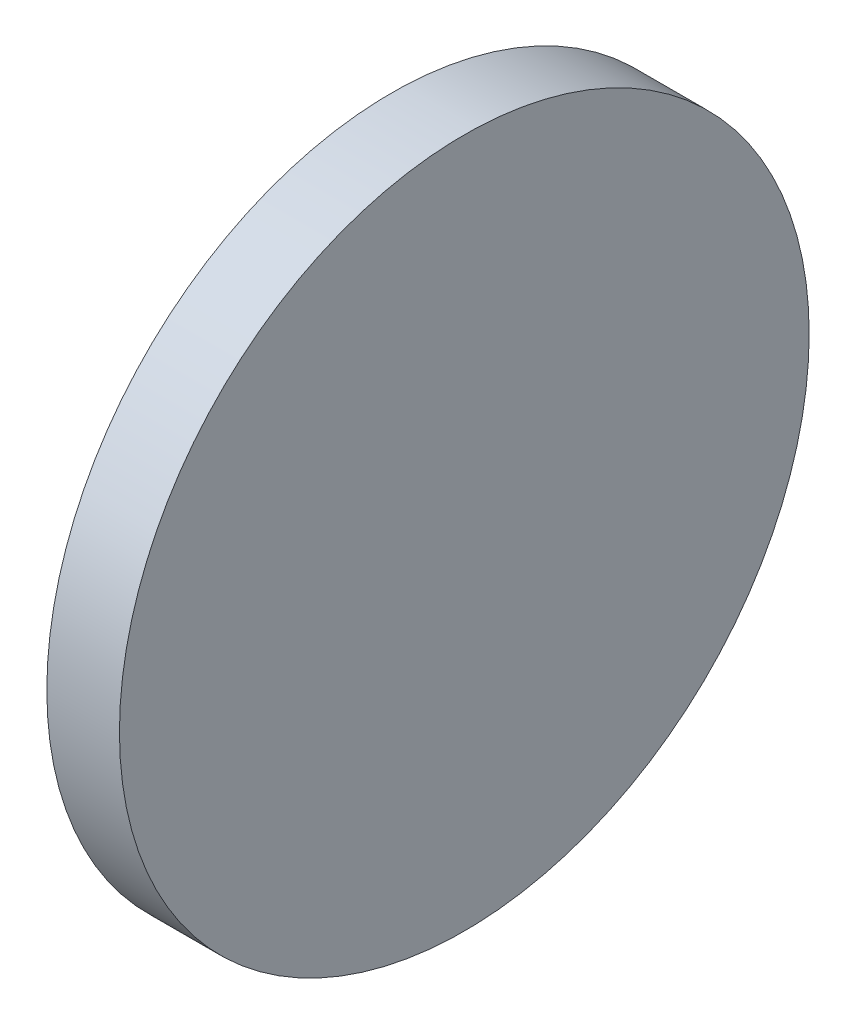
from build123d import *

# Parameters (mm, degrees)
SKETCH_1_W = 4
SKETCH_1_H = 19


with BuildPart() as part:
    # 草图1 → 旋转1 (revolve)
    with BuildSketch(Plane.XY, mode=Mode.PRIVATE) as revolve_1_sk:
        with Locations((262.161702564, 86.793179349)):
            Rectangle(SKETCH_1_W, SKETCH_1_H)
    revolve(revolve_1_sk.sketch.rotate(Axis((254.000801993, 77.293179349, 0), (1, 0, 0)), 90), axis=Axis((254.000801993, 77.293179349, 0), (1, 0, 0)))  # turned: the seam where the file's is


solid = part.part
